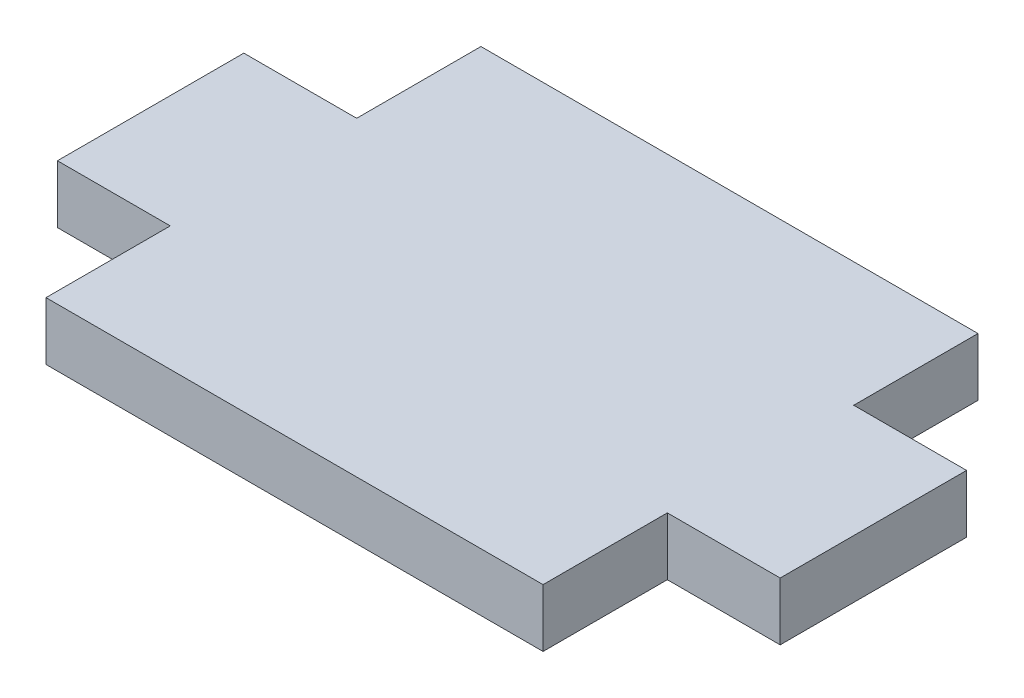
from build123d import *

# Parameters (mm, degrees)
BOSS_EXTRUDE1_DEPTH = 2.9591


with BuildPart() as part:
    # Sketch1 → Boss-Extrude1 (new body)
    with BuildSketch(Plane(origin=(0, 0, 0), x_dir=(1, 0, 0), z_dir=(0, 1, 0))):
        Polygon((-12.7, 11.1125), (12.7, 11.1125), (12.7, 4.7625), (18.4658, 4.7625), (18.4658, -4.7625), (12.7, -4.7625), (12.7, -11.1125), (-12.7, -11.1125), (-12.7, -4.7625), (-18.4658, -4.7625), (-18.4658, 4.7625), (-12.7, 4.7625), align=None)
    extrude(amount=BOSS_EXTRUDE1_DEPTH)


solid = part.part
